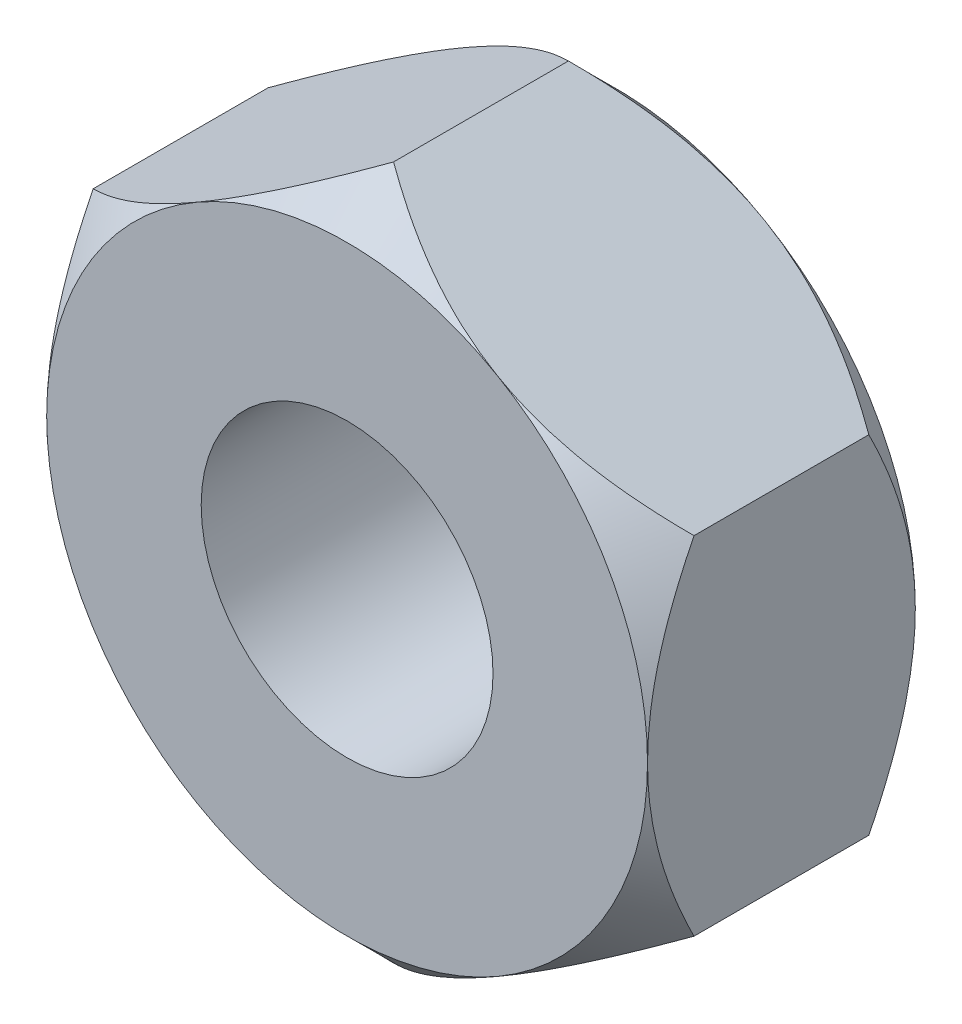
from build123d import *

# Parameters (mm, degrees)
EXTRUDE_6_DEPTH        = 6.24
HOLE_WIZARD_M8_2_D     = 6.8
HOLE_WIZARD_M8_2_DEPTH = 6.24


with BuildPart() as part:
    # 草圖12 → 填料-伸長6 (new body)
    with BuildSketch(Plane.XY):
        Polygon((7, -4.041451884), (7, 4.041451884), (0, 8.082903769), (-7, 4.041451884), (-7, -4.041451884), (0, -8.082903769), align=None)
    extrude(amount=EXTRUDE_6_DEPTH)

    # M8 螺紋孔2
    with Locations(Plane(origin=(0, 0, 0), x_dir=(-1, 0, 0), z_dir=(0, 0, -1))):
        with Locations((0, 0)):
            Hole(HOLE_WIZARD_M8_2_D / 2, depth=HOLE_WIZARD_M8_2_DEPTH)

    # 草圖17 → 除料-旋轉1 (revolve, cut)
    with BuildSketch(Plane(origin=(0, 0, 0), x_dir=(0, 0, -1), z_dir=(1, 0, 0))):
        Polygon((0, 8.082903769), (-1.082903769, 8.082903769), (0, 7), align=None)
        Polygon((-6.24, 7), (-6.24, 8.082903769), (-5.157096231, 8.082903769), align=None)
    revolve(axis=Axis((0, 0, 0), (0, 0, -1)), mode=Mode.SUBTRACT)


solid = part.part
